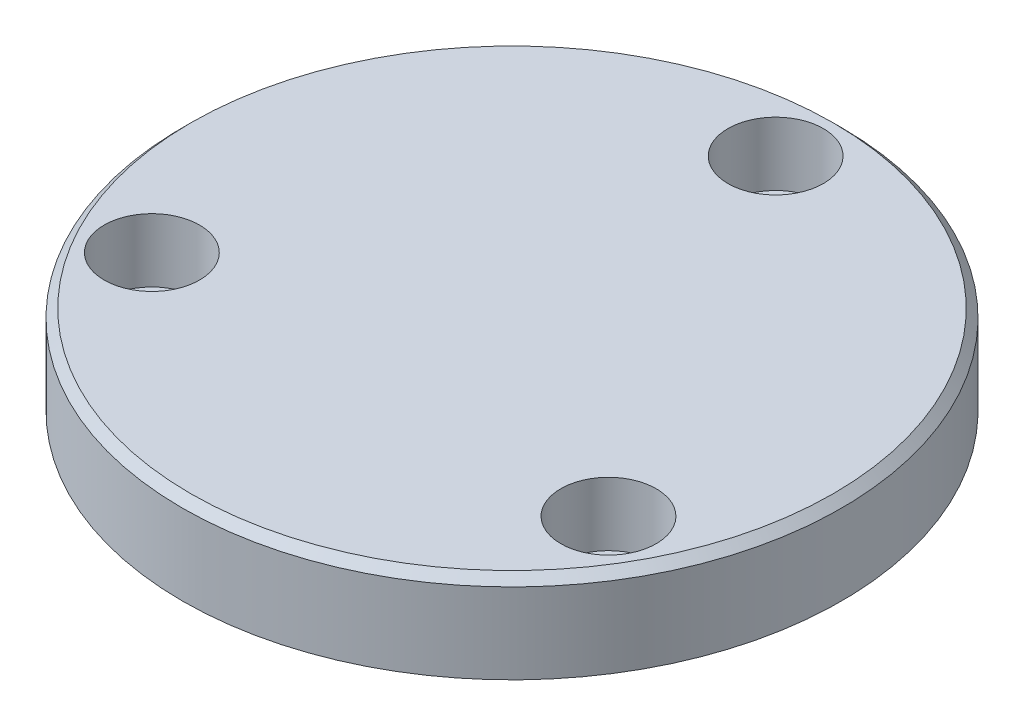
from build123d import *

# Parameters (mm, degrees)
SKETCH1_R                                      = 30.1625
EXTRUDE1_DEPTH                                 = 4.318
CBORE_FOR_8_SOCKET_HEAD_CAP_SCREW1_D           = 4.9149
CBORE_FOR_8_SOCKET_HEAD_CAP_SCREW1_CBORE_D     = 8.73125
CBORE_FOR_8_SOCKET_HEAD_CAP_SCREW1_CBORE_DEPTH = 5.8166
CIRPATTERN1_COUNT                              = 3
SKETCH5_R                                      = 30.1625
SKETCH5_R_2                                    = 4.7625
CUT_EXTRUDE1_DEPTH                             = 0.508
CHAMFER1_SIZE                                  = 0.762


with BuildPart() as part:
    # Sketch1 → Extrude1 (new body, symmetric)
    with BuildSketch(Plane(origin=(0, 0, 0), x_dir=(1, 0, 0), z_dir=(0, 1, 0))):
        with Locations(Location((0, 0, 0), (0, 0, 270))):  # turned: the seam where the file's is
            Circle(SKETCH1_R)
    extrude(amount=EXTRUDE1_DEPTH, both=True)

    # CBORE for _8 Socket Head Cap Screw1 (through all)
    with Locations(Plane(origin=(0, 4.318, 0), x_dir=(-1, 0, 0), z_dir=(0, 1, 0))):
        with Locations((0, -24.13)):
            cbore_for_8_socket_head_cap_screw1 = CounterBoreHole(CBORE_FOR_8_SOCKET_HEAD_CAP_SCREW1_D / 2, CBORE_FOR_8_SOCKET_HEAD_CAP_SCREW1_CBORE_D / 2, CBORE_FOR_8_SOCKET_HEAD_CAP_SCREW1_CBORE_DEPTH)

    # CirPattern1: CBORE for _8 Socket Head Cap Screw1 ×3 about axis
    cirpattern1_axis = Axis((0, 0, 0), (0, 1, 0))
    for i in range(1, CIRPATTERN1_COUNT):
        add(cbore_for_8_socket_head_cap_screw1.rotate(cirpattern1_axis, i * 360 / CIRPATTERN1_COUNT), mode=Mode.SUBTRACT)

    # Sketch5 → Cut-Extrude1 (cut)
    with BuildSketch(Plane.XZ.offset(4.318)):
        with Locations(Location((0, 0, 0), (0, 0, 270))):  # turned: the seam where the file's is
            Circle(SKETCH5_R)
        with Locations(Location((-20.897192993, 12.065, 0), (0, 0, 270))):  # turned: the seam where the file's is
            Circle(SKETCH5_R_2, mode=Mode.SUBTRACT)
        with Locations(Location((0, -24.13, 0), (0, 0, 270))):  # turned: the seam where the file's is
            Circle(SKETCH5_R_2, mode=Mode.SUBTRACT)
        with Locations(Location((20.897192993, 12.065, 0), (0, 0, 270))):  # turned: the seam where the file's is
            Circle(SKETCH5_R_2, mode=Mode.SUBTRACT)
    extrude(amount=-CUT_EXTRUDE1_DEPTH, mode=Mode.SUBTRACT)

    # Chamfer1
    chamfer1_edges = [part.edges().sort_by_distance(p)[0] for p in [
        (0, 4.318, -30.1625),
    ]]
    chamfer(chamfer1_edges, length=CHAMFER1_SIZE)


solid = part.part
